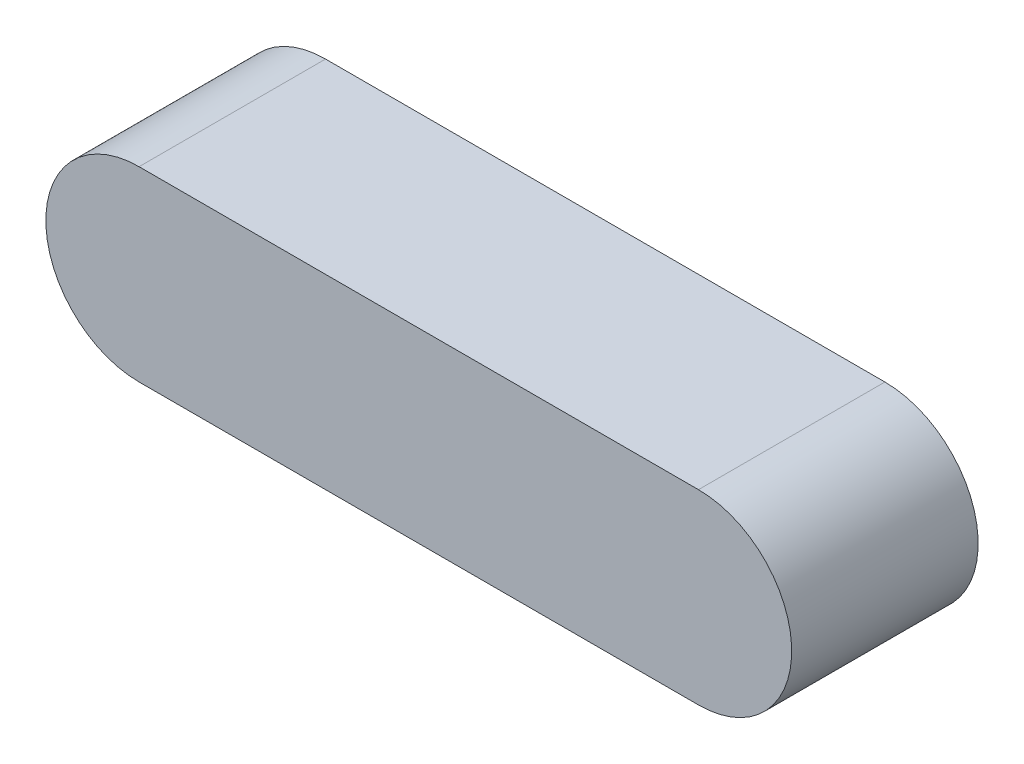
from build123d import *

# Parameters (mm, degrees)
BOSS_EXTRUDE1_DEPTH      = 3.175
BOSS_EXTRUDE1_DEPTH_BACK = 3.175


with BuildPart() as part:
    # Sketch2 → Boss-Extrude1 (new, two sides: drawn at the far end of the back side and taken through both)
    with BuildSketch(Plane.XY.offset(-BOSS_EXTRUDE1_DEPTH_BACK)):
        with BuildLine():
            Line((-9.525, 3.175), (9.525, 3.175))
            ThreePointArc((9.525, 3.175), (12.7, 0), (9.525, -3.175))
            Line((9.525, -3.175), (-9.525, -3.175))
            ThreePointArc((-9.525, -3.175), (-12.7, 0), (-9.525, 3.175))
        make_face()
    extrude(amount=BOSS_EXTRUDE1_DEPTH + BOSS_EXTRUDE1_DEPTH_BACK)


solid = part.part
